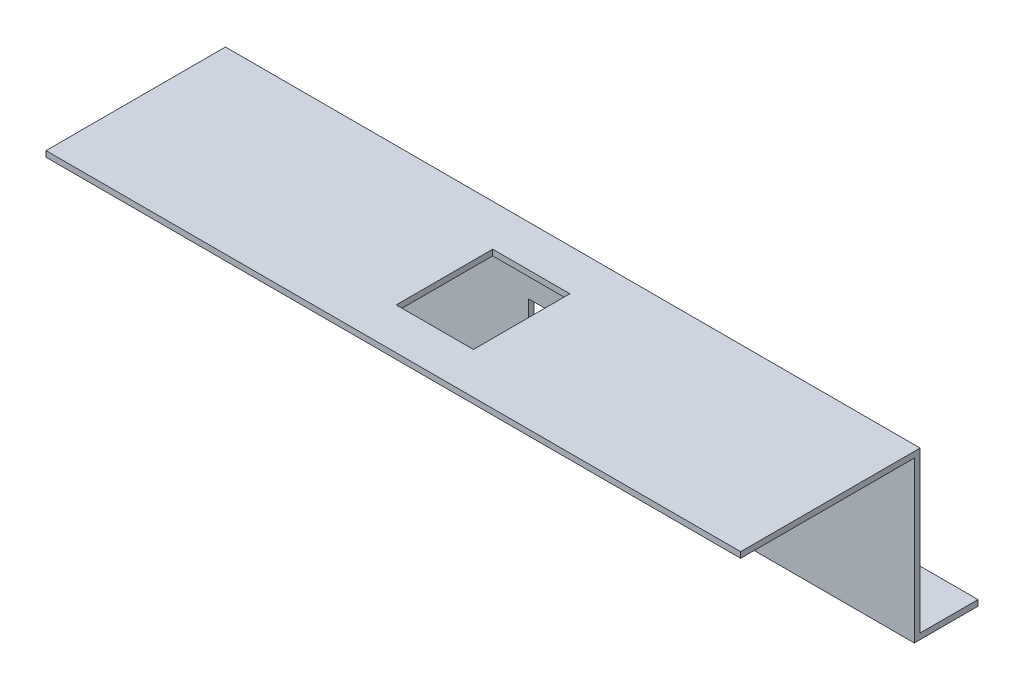
from build123d import *

# Parameters (mm, degrees)
BOSS_EXTRUDE2_DEPTH = 180
SKETCH2_R           = 1.5
CUT_EXTRUDE1_DEPTH  = 10
SKETCH3_W           = 20
SKETCH3_H           = 10
CUT_EXTRUDE2_DEPTH  = 10
SKETCH4_W           = 20
SKETCH4_H           = 25
CUT_EXTRUDE3_DEPTH  = 10


with BuildPart() as part:
    # Sketch1 → Boss-Extrude2 (new body)
    with BuildSketch(Plane(origin=(0, 0, 0), x_dir=(0, 0, -1), z_dir=(1, 0, 0))):
        Polygon((-0.75, 0), (-0.75, 40), (-45.75, 40), (-45.75, 41.5), (0.75, 41.5), (0.75, 0), (15.75, 0), (15.75, -1.5), (-0.75, -1.5), align=None)
    extrude(amount=BOSS_EXTRUDE2_DEPTH)

    # Sketch2 → Cut-Extrude1 (cut)
    with BuildSketch(Plane(origin=(0, 0, 0), x_dir=(1, 0, 0), z_dir=(0, 1, 0))):
        with Locations((120, 8.25)):
            Circle(SKETCH2_R)
        with Locations((90, 8.25)):
            Circle(SKETCH2_R)
        with Locations((150, 8.25)):
            Circle(SKETCH2_R)
        with Locations((60, 8.25)):
            Circle(SKETCH2_R)
        with Locations((30, 8.25)):
            Circle(SKETCH2_R)
    extrude(amount=-CUT_EXTRUDE1_DEPTH, mode=Mode.SUBTRACT)

    # Sketch3 → Cut-Extrude2 (cut)
    with BuildSketch(Plane(origin=(0, 0, -0.75), x_dir=(-1, 0, 0), z_dir=(0, 0, -1))):
        with Locations((-90, 20.75)):
            Rectangle(SKETCH3_W, SKETCH3_H)
    extrude(amount=-CUT_EXTRUDE2_DEPTH, mode=Mode.SUBTRACT)

    # Sketch4 → Cut-Extrude3 (cut)
    with BuildSketch(Plane(origin=(0, 41.5, 0), x_dir=(1, 0, 0), z_dir=(0, 1, 0))):
        with Locations((90, -22.5)):
            Rectangle(SKETCH4_W, SKETCH4_H)
    extrude(amount=-CUT_EXTRUDE3_DEPTH, mode=Mode.SUBTRACT)


solid = part.part
